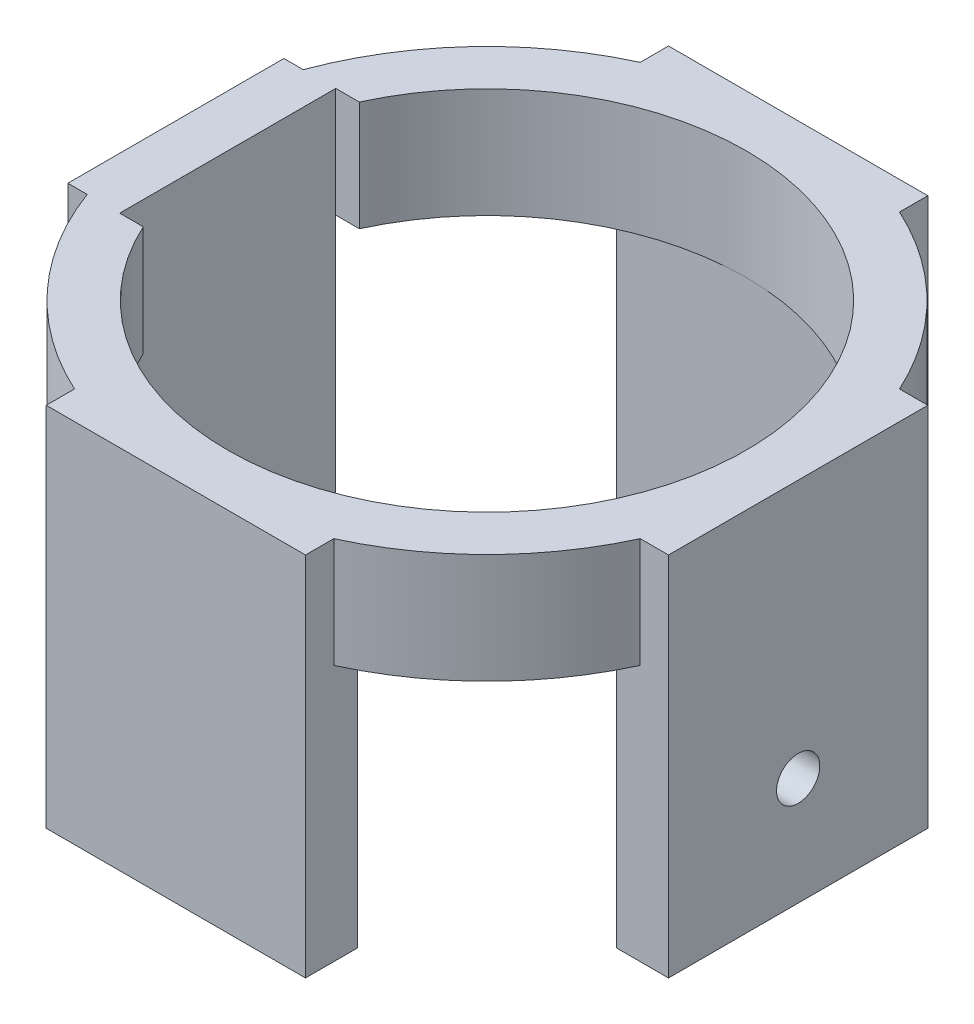
from build123d import *

# Parameters (mm, degrees)
SKETCH1_R                       = 72
SKETCH1_R_2                     = 60
BOSS_EXTRUDE1_DEPTH             = 25.4
BOSS_EXTRUDE4_DEPTH             = 12
CUT_EXTRUDE1_DEPTH              = 25.4
SKETCH8_W                       = 60
SKETCH8_H                       = 84.7705
BOSS_EXTRUDE5_DEPTH             = 12
CIRPATTERN4_COUNT               = 2
CIRPATTERN4_ANGLE               = 90
CIRPATTERN4_THE_OTHER_WAY_COUNT = 2
CIRPATTERN4_THE_OTHER_WAY_ANGLE = 90
M8_CLEARANCE_HOLE1_D            = 10
M8_CLEARANCE_HOLE1_DEPTH        = 12


with BuildPart() as part:
    # Sketch1 → Boss-Extrude1 (new body)
    with BuildSketch(Plane(origin=(0, 0, 0), x_dir=(1, 0, 0), z_dir=(0, 1, 0))):
        Circle(SKETCH1_R)
        Circle(SKETCH1_R_2, mode=Mode.SUBTRACT)
    extrude(amount=-BOSS_EXTRUDE1_DEPTH)

    # Sketch7 → Boss-Extrude4 (add)
    with BuildSketch(Plane(origin=(-60, 0, 0), x_dir=(0, 0, -1), z_dir=(1, 0, 0))):
        Polygon((-25, -25.4), (-25, -81.8336), (25, -81.8336), (25, -25.4), (25, 0), (-25, 0), align=None)
    extrude(amount=-BOSS_EXTRUDE4_DEPTH)

    # Sketch15 → Cut-Extrude1 (cut)
    with BuildSketch(Plane.XZ.offset(25.4)):
        Polygon((-60, 25), (-54.543560573, 25), (-54.543560573, -25), (-60, -25), (-60, 0), align=None)
    extrude(amount=-CUT_EXTRUDE1_DEPTH, mode=Mode.SUBTRACT)

    # Sketch8 → Boss-Extrude5 (add)
    with BuildSketch(Plane.ZY.offset(-60)):
        with Locations((0, -42.38525)):
            Rectangle(SKETCH8_W, SKETCH8_H)
    boss_extrude5 = extrude(amount=-BOSS_EXTRUDE5_DEPTH)

    # CirPattern4: Boss-Extrude5 ×2 about axis
    cirpattern4_axis = Axis((0, 0, 0), (0, 1, 0))
    for i in range(1, CIRPATTERN4_COUNT):
        add(boss_extrude5.rotate(cirpattern4_axis, i * CIRPATTERN4_ANGLE / (CIRPATTERN4_COUNT - 1)))

    # CirPattern4 the other way: Boss-Extrude5 ×2 about axis
    cirpattern4_the_other_way_axis = Axis((0, 0, 0), (0, -1, 0))
    for i in range(1, CIRPATTERN4_THE_OTHER_WAY_COUNT):
        add(boss_extrude5.rotate(cirpattern4_the_other_way_axis, i * CIRPATTERN4_THE_OTHER_WAY_ANGLE / (CIRPATTERN4_THE_OTHER_WAY_COUNT - 1)))

    # M8 Clearance Hole1
    with Locations(Plane.ZY.offset(-60)):
        with Locations((0, -59.7705)):
            Hole(M8_CLEARANCE_HOLE1_D / 2, depth=M8_CLEARANCE_HOLE1_DEPTH)


solid = part.part
